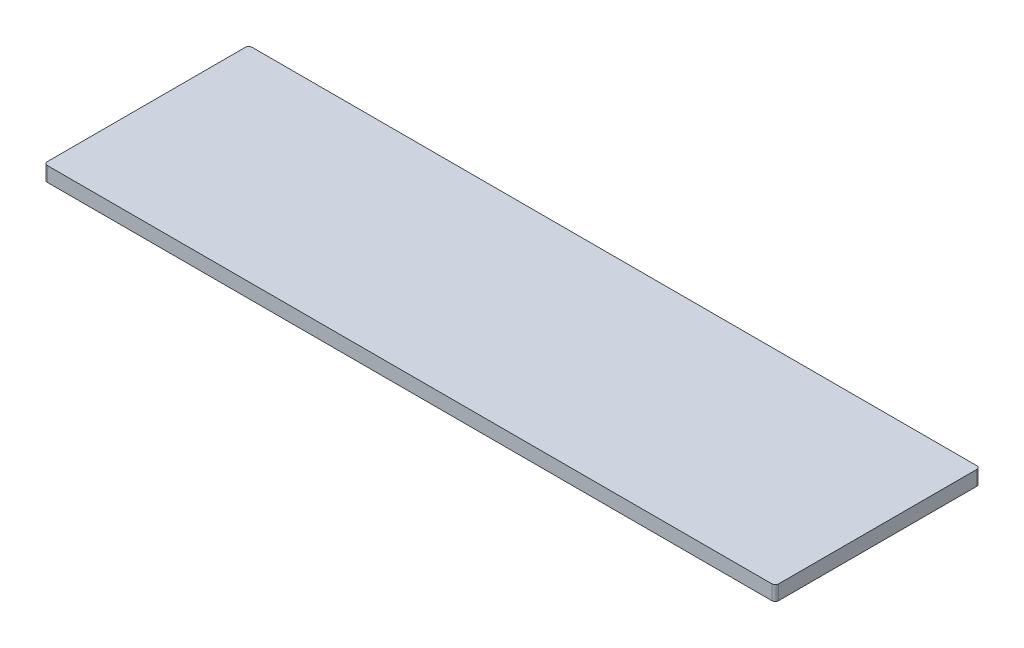
from build123d import *

# Parameters (mm, degrees)
SKETCH1_W           = 635
SKETCH1_H           = 177.8
BOSS_EXTRUDE1_DEPTH = 12.7
FILLET1_R           = 3


with BuildPart() as part:
    # Sketch1 → Boss-Extrude1 (new body)
    with BuildSketch(Plane(origin=(0, 0, 0), x_dir=(1, 0, 0), z_dir=(0, 1, 0))):
        Rectangle(SKETCH1_W, SKETCH1_H)
    extrude(amount=BOSS_EXTRUDE1_DEPTH)

    # Fillet1
    fillet1_edges = [part.edges().sort_by_distance(p)[0] for p in [
        (317.5, 6.35, 88.9),
        (-317.5, 6.35, 88.9),
        (-317.5, 6.35, -88.9),
        (317.5, 6.35, -88.9),
    ]]
    fillet(fillet1_edges, radius=FILLET1_R)


solid = part.part
